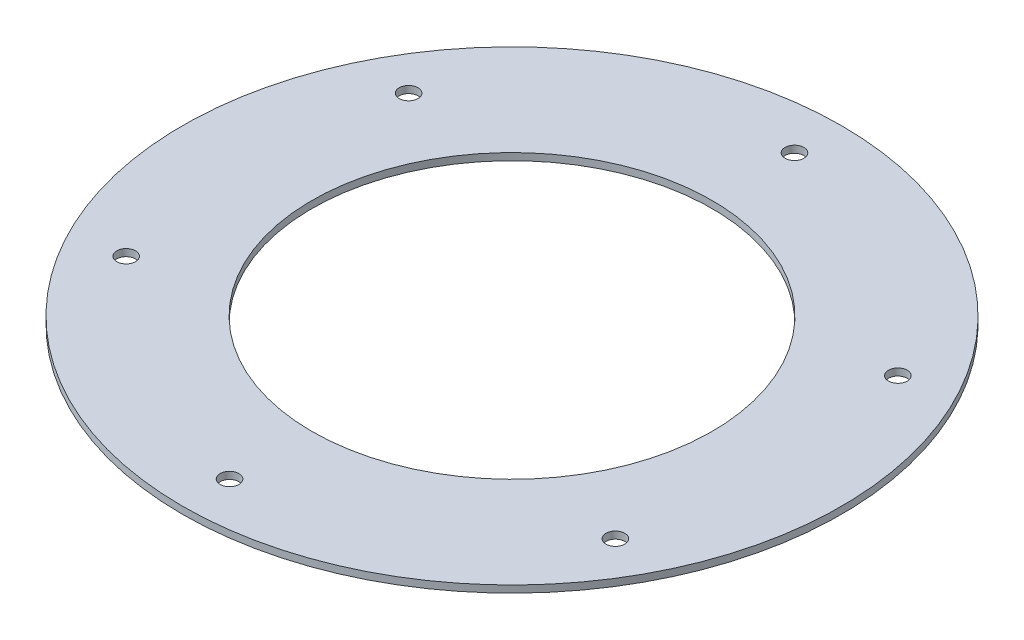
from build123d import *

# Parameters (mm, degrees)
CROQUIS1_R              = 140
CROQUIS1_R_2            = 85
SALIENTE_EXTRUIR1_DEPTH = 3
CROQUIS2_R              = 4
CORTAR_EXTRUIR1_DEPTH   = 4


with BuildPart() as part:
    # Croquis1 → Saliente-Extruir1 (new body)
    with BuildSketch(Plane(origin=(0, 0, 0), x_dir=(1, 0, 0), z_dir=(0, 1, 0))):
        Circle(CROQUIS1_R)
        Circle(CROQUIS1_R_2, mode=Mode.SUBTRACT)
    extrude(amount=SALIENTE_EXTRUIR1_DEPTH)

    # Croquis2 → Cortar-Extruir1 (cut, through all)
    with BuildSketch(Plane(origin=(0, 3, 0), x_dir=(1, 0, 0), z_dir=(0, 1, 0))):
        with Locations((0, 120)):
            Circle(CROQUIS2_R)
        with Locations((103.923048454, 60)):
            Circle(CROQUIS2_R)
        with Locations((103.923048454, -60)):
            Circle(CROQUIS2_R)
        with Locations((0, -120)):
            Circle(CROQUIS2_R)
        with Locations((-103.923048454, -60)):
            Circle(CROQUIS2_R)
        with Locations((-103.923048454, 60)):
            Circle(CROQUIS2_R)
    extrude(amount=-CORTAR_EXTRUIR1_DEPTH, mode=Mode.SUBTRACT)


solid = part.part
